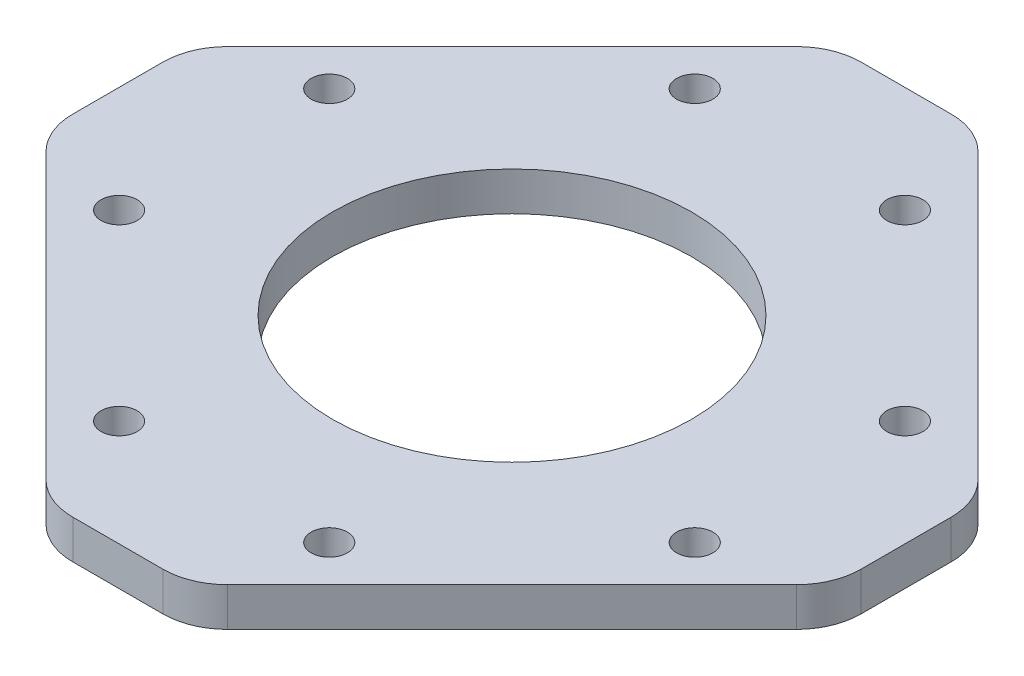
from build123d import *

# Parameters (mm, degrees)
SKETCH1_R           = 13.9
SKETCH1_R_2         = 1.4
BOSS_EXTRUDE1_DEPTH = 3


with BuildPart() as part:
    # Sketch1 → Boss-Extrude1 (new body)
    with BuildSketch(Plane(origin=(0, 0, 0), x_dir=(1, 0, 0), z_dir=(0, 1, 0))):
        with BuildLine():
            Line((3.491378029, 30.5), (-3.491378029, 30.5))
            ThreePointArc((-3.491378029, 30.5), (-5.40479519, 30.119397663), (-7.026911935, 29.035533906))
            Line((-7.026911935, 29.035533906), (-29.035533906, 7.026911935))
            ThreePointArc((-29.035533906, 7.026911935), (-30.119397663, 5.40479519), (-30.5, 3.491378029))
            Line((-30.5, 3.491378029), (-30.5, -3.491378029))
            ThreePointArc((-30.5, -3.491378029), (-30.119397663, -5.40479519), (-29.035533906, -7.026911935))
            Line((-29.035533906, -7.026911935), (-7.026911935, -29.035533906))
            ThreePointArc((-7.026911935, -29.035533906), (-5.40479519, -30.119397663), (-3.491378029, -30.5))
            Line((-3.491378029, -30.5), (3.491378029, -30.5))
            ThreePointArc((3.491378029, -30.5), (5.40479519, -30.119397663), (7.026911935, -29.035533906))
            Line((7.026911935, -29.035533906), (29.035533906, -7.026911935))
            ThreePointArc((29.035533906, -7.026911935), (30.119397663, -5.40479519), (30.5, -3.491378029))
            Line((30.5, -3.491378029), (30.5, 3.491378029))
            ThreePointArc((30.5, 3.491378029), (30.119397663, 5.40479519), (29.035533906, 7.026911935))
            Line((29.035533906, 7.026911935), (7.026911935, 29.035533906))
            ThreePointArc((7.026911935, 29.035533906), (5.40479519, 30.119397663), (3.491378029, 30.5))
        make_face()
        Circle(SKETCH1_R, mode=Mode.SUBTRACT)
        with Locations((8.131727984, -22.273863607)):
            Circle(SKETCH1_R_2, mode=Mode.SUBTRACT)
        with Locations((-8.131727984, -22.273863607)):
            Circle(SKETCH1_R_2, mode=Mode.SUBTRACT)
        with Locations((-22.273863607, -8.131727984)):
            Circle(SKETCH1_R_2, mode=Mode.SUBTRACT)
        with Locations((22.273863607, -8.131727984)):
            Circle(SKETCH1_R_2, mode=Mode.SUBTRACT)
        with Locations((22.273863607, 8.131727984)):
            Circle(SKETCH1_R_2, mode=Mode.SUBTRACT)
        with Locations((8.131727984, 22.273863607)):
            Circle(SKETCH1_R_2, mode=Mode.SUBTRACT)
        with Locations((-8.131727984, 22.273863607)):
            Circle(SKETCH1_R_2, mode=Mode.SUBTRACT)
        with Locations((-22.273863607, 8.131727984)):
            Circle(SKETCH1_R_2, mode=Mode.SUBTRACT)
    extrude(amount=BOSS_EXTRUDE1_DEPTH)


solid = part.part
